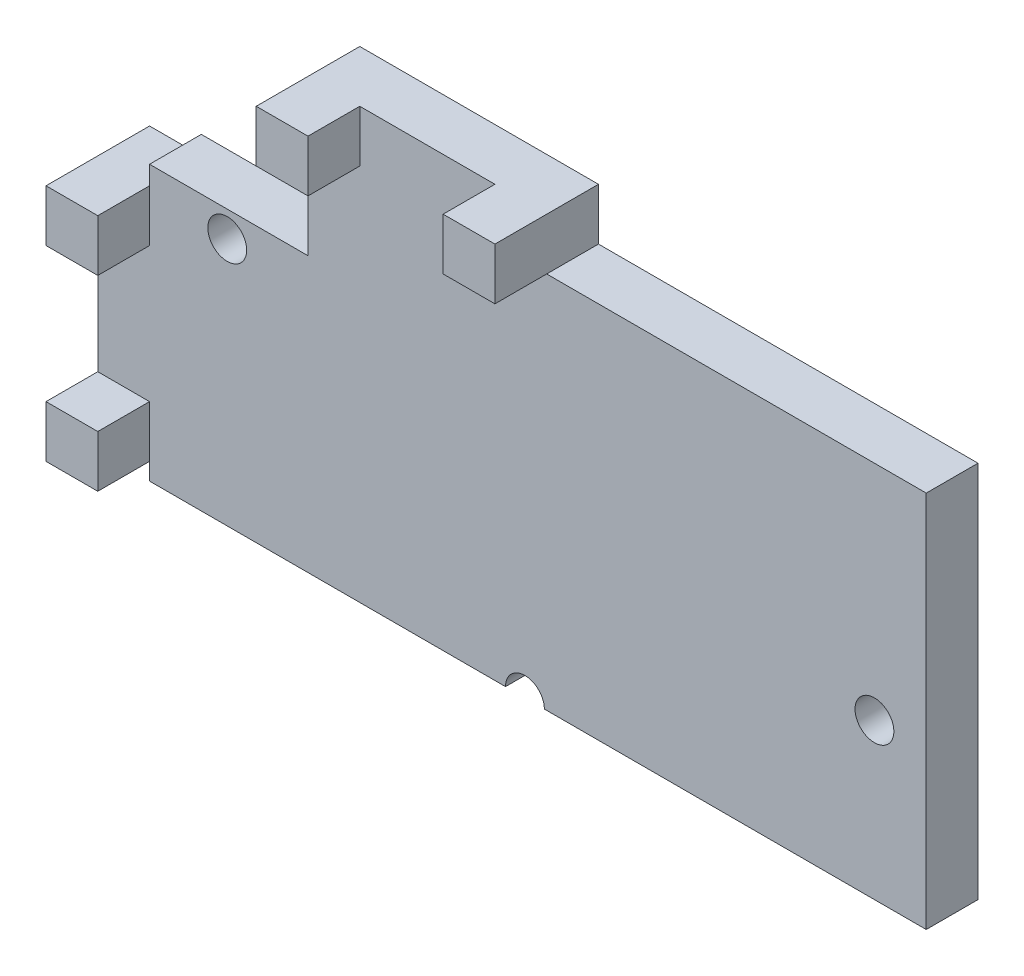
from build123d import *

# Parameters (mm, degrees)
SKETCH1_W              = 15
SKETCH1_H              = 7.3
BASE_EXTRUDE1_DEPTH    = 1
NOTCH_W                = 3.06
NOTCH_H                = 2
CUT_EXTRUDE1_DEPTH     = 1
SKETCH5_W              = 4.61
SKETCH5_H              = 1
TOP_LED_EXTRUDE_DEPTH  = 1
SKETCH6_W              = 1
SKETCH6_H              = 1
TOP_CLAMP_DEPTH        = 1
SKETCH7_W              = 1
SKETCH7_H              = 4.61
SIDE_LED_EXTRUDE_DEPTH = 1
SKETCH8_W              = 1
SKETCH8_H              = 1
SIDE_CLAMP_DEPTH       = 1
SKETCH9_R              = 0.375
SCREWHOLES_DEPTH       = 1


with BuildPart() as part:
    # Sketch1 → Base-Extrude1 (new body)
    with BuildSketch(Plane.XY):
        with Locations((1.905405405, 0.163513514)):
            Rectangle(SKETCH1_W, SKETCH1_H)
    extrude(amount=BASE_EXTRUDE1_DEPTH)

    # Notch → Cut-Extrude1 (cut)
    with BuildSketch(Plane(origin=(0, 0, 0), x_dir=(-1, 0, 0), z_dir=(0, 0, -1))):
        with Locations((4.064594595, 2.813513514)):
            Rectangle(NOTCH_W, NOTCH_H)
    extrude(amount=-CUT_EXTRUDE1_DEPTH, mode=Mode.SUBTRACT)

    # Sketch5 → Top-LED-Extrude (add)
    with BuildSketch(Plane.XY.offset(1)):
        with Locations((-0.229594595, 4.313513514)):
            Rectangle(SKETCH5_W, SKETCH5_H)
    extrude(amount=-TOP_LED_EXTRUDE_DEPTH)

    # Sketch6 → Top-Clamp (add)
    with BuildSketch(Plane.XY.offset(1)):
        with Locations((-2.034594595, 4.313513514)):
            Rectangle(SKETCH6_W, SKETCH6_H)
        with Locations((1.575405405, 4.313513514)):
            Rectangle(SKETCH6_W, SKETCH6_H)
    extrude(amount=TOP_CLAMP_DEPTH)

    # Sketch7 → Side-LED-Extrude (add)
    with BuildSketch(Plane.ZY.offset(5.594594595)):
        with Locations((0.5, -0.851486486)):
            Rectangle(SKETCH7_W, SKETCH7_H)
    extrude(amount=SIDE_LED_EXTRUDE_DEPTH)

    # Sketch8 → Side-Clamp (add)
    with BuildSketch(Plane.XY.offset(1)):
        with Locations((-6.094594595, -2.656486486)):
            Rectangle(SKETCH8_W, SKETCH8_H)
        with Locations((-6.094594595, 0.953513514)):
            Rectangle(SKETCH8_W, SKETCH8_H)
    extrude(amount=SIDE_CLAMP_DEPTH)

    # Sketch9 → ScrewHoles (cut)
    with BuildSketch(Plane(origin=(0, 0, 0), x_dir=(-1, 0, 0), z_dir=(0, 0, -1))):
        with Locations((-8.405405405, -0.486486486)):
            Circle(SKETCH9_R)
        with Locations((4.094594595, 1.313513514)):
            Circle(SKETCH9_R)
        with Locations((-1.655405405, -3.486486486)):
            Circle(SKETCH9_R)
    extrude(amount=-SCREWHOLES_DEPTH, mode=Mode.SUBTRACT)


solid = part.part
